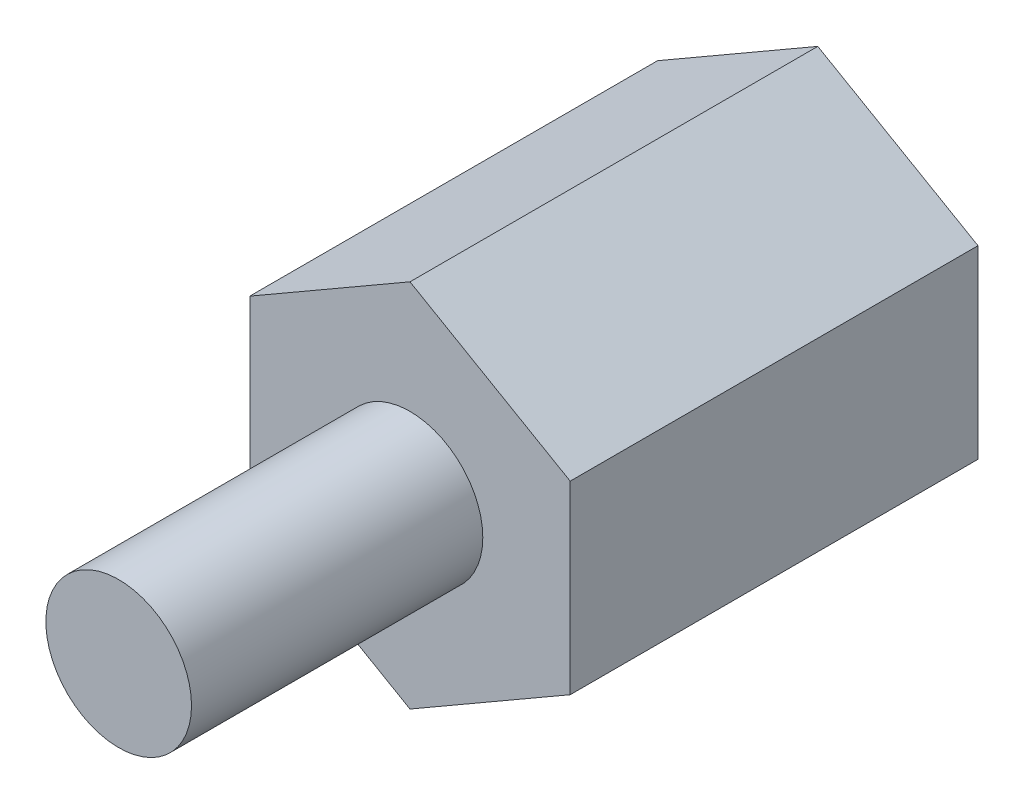
from build123d import *

# Parameters (mm, degrees)
EXTRUSION1_DEPTH      = 6
EXTRUSION1_DEPTH_BACK = 6
SKETCH2_R             = 1.25
EXTRUSION2_DEPTH      = 4
SKETCH3_R             = 1.25
THREAD2_DEPTH         = 5


with BuildPart() as part:
    # Sketch1 → Extrusion1 (new body, two sides)
    with BuildSketch(Plane.XY) as extrusion1_sk:
        Polygon((0, 3.175426481), (-2.75, 1.58771324), (-2.75, -1.58771324), (0, -3.175426481), (2.75, -1.58771324), (2.75, 1.58771324), align=None)
    extrude(amount=EXTRUSION1_DEPTH)
    extrude(extrusion1_sk.sketch, amount=-EXTRUSION1_DEPTH_BACK)

    # Sketch2 → Extrusion2 (cut)
    with BuildSketch(Plane(origin=(0, 0, -6), x_dir=(-1, 0, 0), z_dir=(0, 0, -1))):
        Circle(SKETCH2_R)
    extrude(amount=-EXTRUSION2_DEPTH, mode=Mode.SUBTRACT)

    # Sketch3 → Thread2 (cut)
    with BuildSketch(Plane.XY.offset(6)):
        Polygon((2.75, -1.58771324), (2.75, 1.58771324), (0, 3.175426481), (-2.75, 1.58771324), (-2.75, -1.58771324), (0, -3.175426481), align=None)
        Circle(SKETCH3_R, mode=Mode.SUBTRACT)
    extrude(amount=-THREAD2_DEPTH, mode=Mode.SUBTRACT)


solid = part.part
